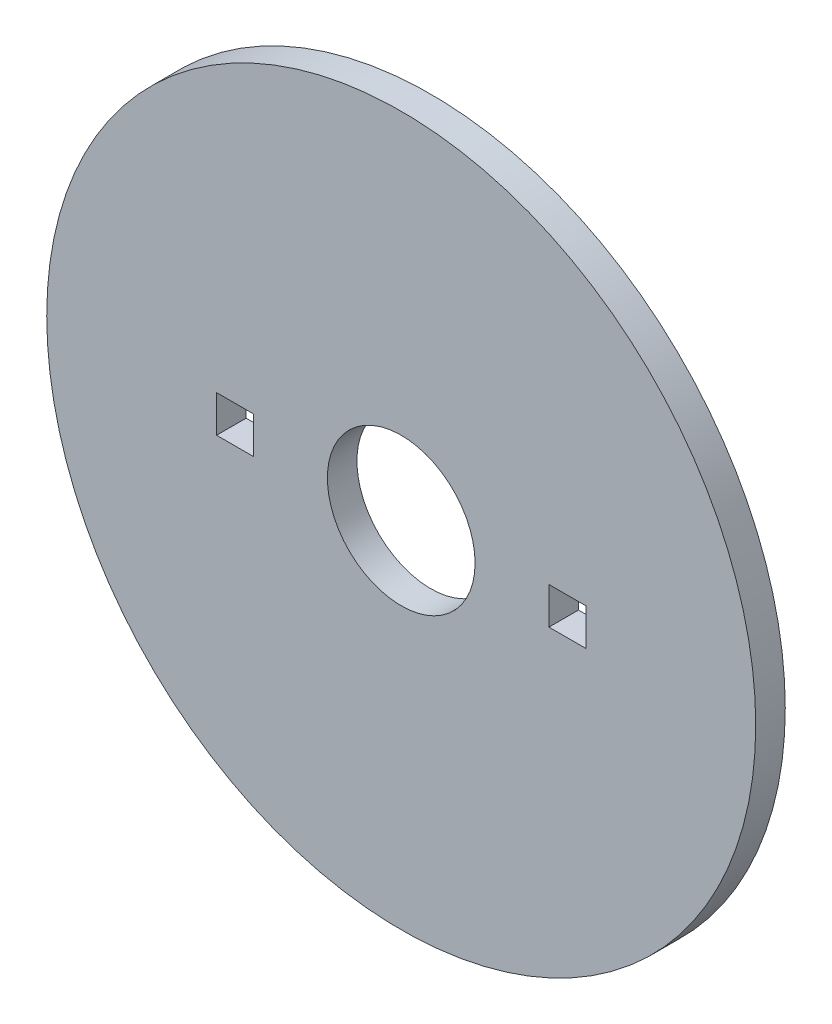
from build123d import *

# Parameters (mm, degrees)
SKETCH1_R               = 9.6
BOSS_EXTRUDE1_DEPTH     = 0.8
CUT_EXTRUDE4_START      = 0.8
SKETCH3_R               = 2
SKETCH3_W               = 1
SKETCH3_H               = 1
CUT_EXTRUDE4_DEPTH      = 1.8
CUT_EXTRUDE4_DEPTH_BACK = 1.8


with BuildPart() as part:
    # Sketch1 → Boss-Extrude1 (new body)
    with BuildSketch(Plane.XY):
        Circle(SKETCH1_R)
    extrude(amount=BOSS_EXTRUDE1_DEPTH)

    # Sketch3 → Cut-Extrude4 (cut, two sides)
    with BuildSketch(Plane.XY.offset(CUT_EXTRUDE4_START)) as cut_extrude4_sk:
        Circle(SKETCH3_R)
        with Locations((-4.5, 0)):
            Rectangle(SKETCH3_W, SKETCH3_H)
        with Locations((4.5, 0)):
            Rectangle(SKETCH3_W, SKETCH3_H)
    extrude(amount=CUT_EXTRUDE4_DEPTH, mode=Mode.SUBTRACT)
    extrude(cut_extrude4_sk.sketch, amount=-CUT_EXTRUDE4_DEPTH_BACK, mode=Mode.SUBTRACT)


solid = part.part
